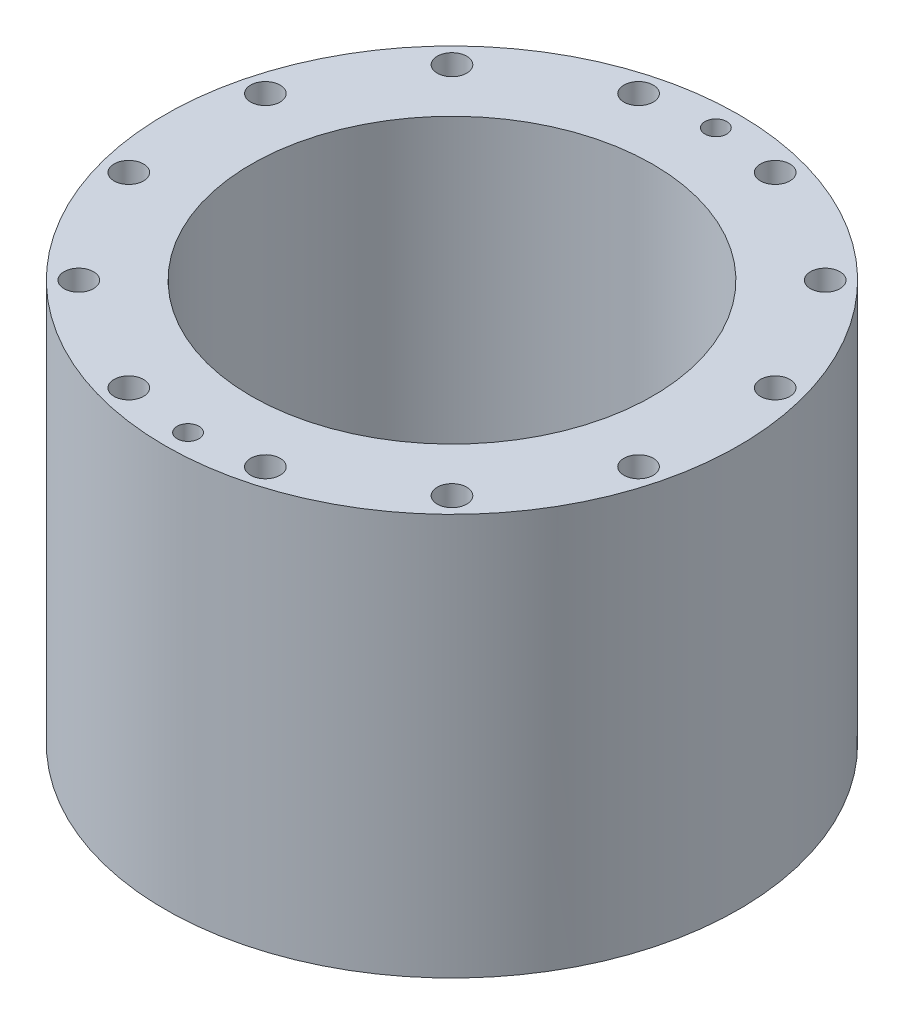
from build123d import *

# Parameters (mm, degrees)
SKETCH2_R               = 55.88
SKETCH2_R_2             = 44.45
BASE_CYLINDER_DEPTH     = 88.9
SKETCH3_R               = 63.5
SKETCH3_R_2             = 44.45
AFT_FLANGE_DEPTH        = 88.9
SKETCH6_R               = 50.9524
SKETCH6_R_2             = 47.4218
AFT_O_RING_DEPTH        = 1.9812
SKETCH_FOR_BOLT_HOLES_R = 3.2639
CUT_EXTRUDE1_DEPTH      = 89.9
SKETCH51_R              = 2.413
CUT_EXTRUDE2_DEPTH      = 4.826


with BuildPart() as part:
    # Sketch2 → Base Cylinder (new body)
    with BuildSketch(Plane(origin=(0, 0, 0), x_dir=(1, 0, 0), z_dir=(0, 1, 0))):
        Circle(SKETCH2_R)
        Circle(SKETCH2_R_2, mode=Mode.SUBTRACT)
    extrude(amount=BASE_CYLINDER_DEPTH)

    # Sketch3 → Aft Flange (add)
    with BuildSketch(Plane.XZ):
        Circle(SKETCH3_R)
        Circle(SKETCH3_R_2, mode=Mode.SUBTRACT)
    extrude(amount=-AFT_FLANGE_DEPTH)

    # Sketch6 → Aft O-Ring (cut)
    with BuildSketch(Plane.XZ):
        Circle(SKETCH6_R)
        Circle(SKETCH6_R_2, mode=Mode.SUBTRACT)
    extrude(amount=-AFT_O_RING_DEPTH, mode=Mode.SUBTRACT)

    # Sketch For Bolt Holes → Cut-Extrude1 (cut, through all)
    with BuildSketch(Plane.XZ):
        with Locations((15.120208615, 56.429386772)):
            Circle(SKETCH_FOR_BOLT_HOLES_R)
        with Locations((41.309178157, 41.309178157)):
            Circle(SKETCH_FOR_BOLT_HOLES_R)
        with Locations((56.429386772, 15.120208615)):
            Circle(SKETCH_FOR_BOLT_HOLES_R)
        with Locations((56.429386772, -15.120208615)):
            Circle(SKETCH_FOR_BOLT_HOLES_R)
        with Locations((41.309178157, -41.309178157)):
            Circle(SKETCH_FOR_BOLT_HOLES_R)
        with Locations((15.120208615, -56.429386772)):
            Circle(SKETCH_FOR_BOLT_HOLES_R)
        with Locations((-15.120208615, -56.429386772)):
            Circle(SKETCH_FOR_BOLT_HOLES_R)
        with Locations((-41.309178157, -41.309178157)):
            Circle(SKETCH_FOR_BOLT_HOLES_R)
        with Locations((-56.429386772, -15.120208615)):
            Circle(SKETCH_FOR_BOLT_HOLES_R)
        with Locations((-56.429386772, 15.120208615)):
            Circle(SKETCH_FOR_BOLT_HOLES_R)
        with Locations((-41.309178157, 41.309178157)):
            Circle(SKETCH_FOR_BOLT_HOLES_R)
        with Locations((-15.120208615, 56.429386772)):
            Circle(SKETCH_FOR_BOLT_HOLES_R)
    extrude(amount=-CUT_EXTRUDE1_DEPTH, mode=Mode.SUBTRACT)

    # Sketch51 → Cut-Extrude2 (cut)
    with BuildSketch(Plane(origin=(0, 88.9, 0), x_dir=(1, 0, 0), z_dir=(0, 1, 0))):
        with Locations((0, 58.42)):
            Circle(SKETCH51_R)
        with Locations((0, -58.42)):
            Circle(SKETCH51_R)
    extrude(amount=-CUT_EXTRUDE2_DEPTH, mode=Mode.SUBTRACT)


solid = part.part
